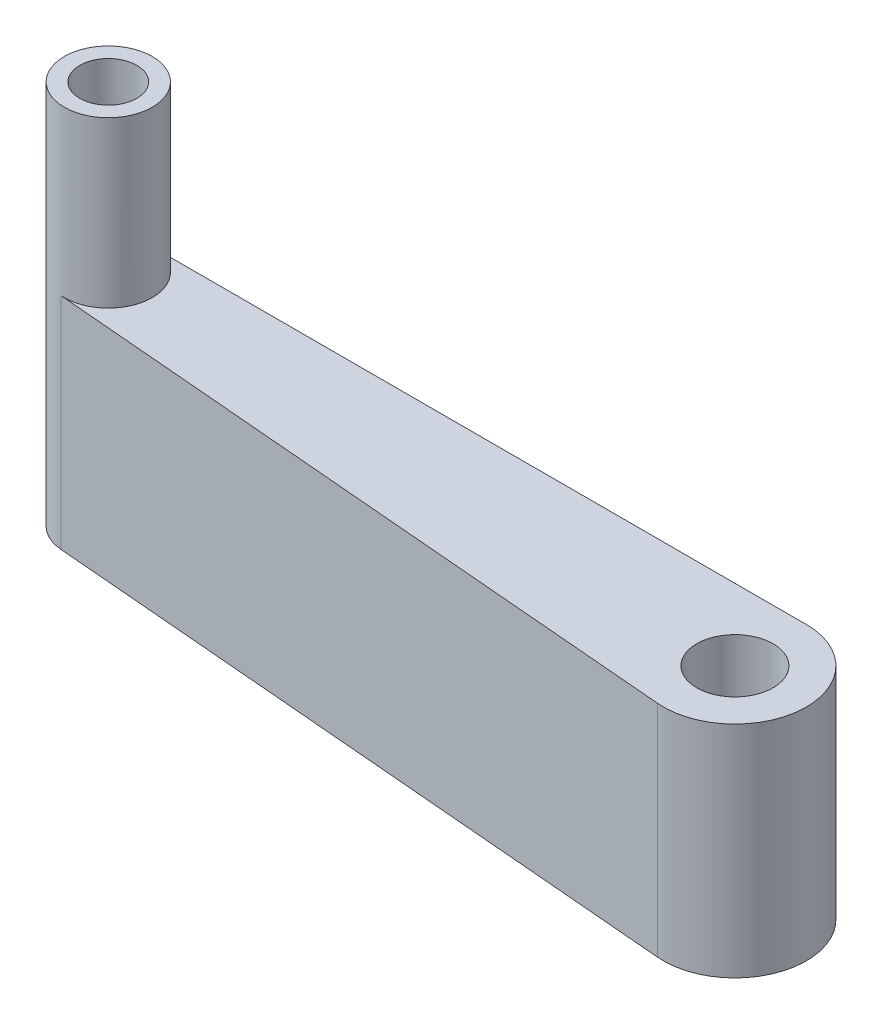
from build123d import *

# Parameters (mm, degrees)
SALIENTE_EXTRUIR1_DEPTH = 10
CROQUIS2_R              = 3.475
CORTAR_EXTRUIR1_DEPTH   = 21
CROQUIS3_R              = 4
SALIENTE_EXTRUIR2_DEPTH = 15
CROQUIS4_R              = 2.6
CORTAR_EXTRUIR2_DEPTH   = 6


with BuildPart() as part:
    # Croquis1 → Saliente-Extruir1 (new body, symmetric)
    with BuildSketch(Plane(origin=(0, 0, 0), x_dir=(1, 0, 0), z_dir=(0, 1, 0))):
        with BuildLine():
            Line((-59.5, 6.5), (0, 6.5))
            ThreePointArc((0, 6.5), (6.494269997, -0.272868487), (-0.545255886, -6.477090089))
            Line((-0.545255886, -6.477090089), (-59.835542084, -1.485901593))
            ThreePointArc((-59.835542084, -1.485901593), (-63.496473844, 2.667919069), (-59.5, 6.5))
        make_face()
    extrude(amount=SALIENTE_EXTRUIR1_DEPTH, both=True)

    # Croquis2 → Cortar-Extruir1 (cut, through all)
    with BuildSketch(Plane(origin=(0, 10, 0), x_dir=(1, 0, 0), z_dir=(0, 1, 0))):
        Circle(CROQUIS2_R)
    extrude(amount=-CORTAR_EXTRUIR1_DEPTH, mode=Mode.SUBTRACT)

    # Croquis3 → Saliente-Extruir2 (add)
    with BuildSketch(Plane(origin=(0, 10, 0), x_dir=(1, 0, 0), z_dir=(0, 1, 0))):
        with Locations((-59.5, 2.5)):
            Circle(CROQUIS3_R)
    extrude(amount=SALIENTE_EXTRUIR2_DEPTH)

    # Croquis4 → Cortar-Extruir2 (cut)
    with BuildSketch(Plane(origin=(0, 25, 0), x_dir=(1, 0, 0), z_dir=(0, 1, 0))):
        with Locations((-59.5, 2.5)):
            Circle(CROQUIS4_R)
    extrude(amount=-CORTAR_EXTRUIR2_DEPTH, mode=Mode.SUBTRACT)


solid = part.part
